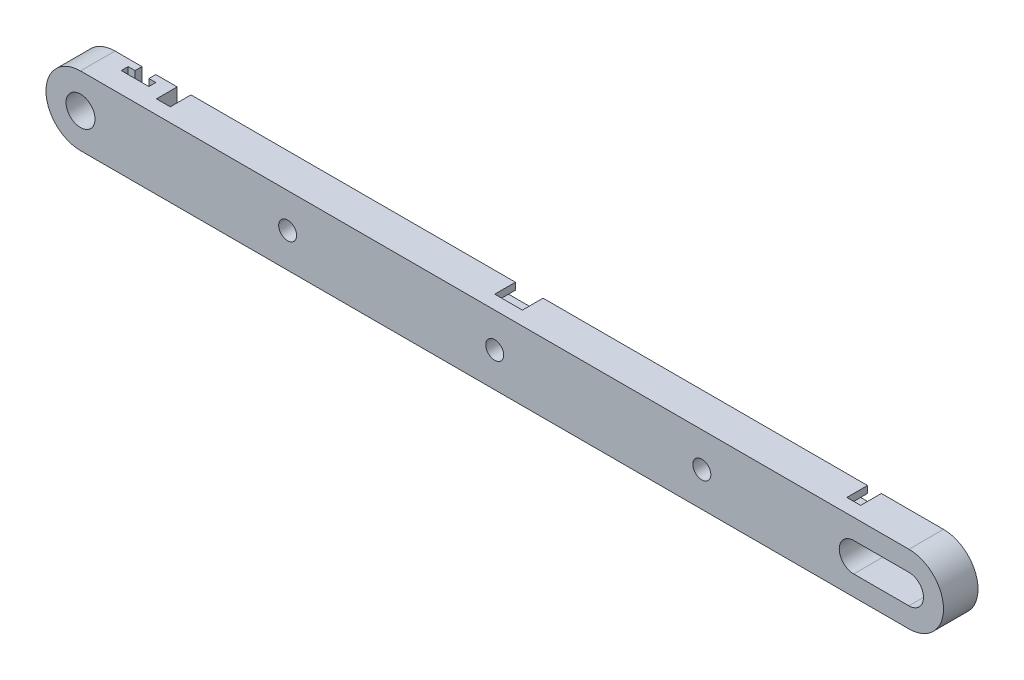
from build123d import *

# Parameters (mm, degrees)
ESQUISSE1_R                  = 10.5
BOSS_EXTRU_1_DEPTH           = 25
ENL_V_START                  = -15
ENL_V_MAT_EXTRU_1_DEPTH      = 35
ENL_V_MAT_EXTRU_2_DEPTH      = 50
ENL_V_MAT_EXTRU_3_DEPTH      = 15
ENL_V_MAT_EXTRU_4_DEPTH      = 626.999201278
ENL_V_MAT_EXTRU_4_DEPTH_BACK = 626.999201278
ESQUISSE1_4_R                = 6.500000002
ESQUISSE1_5_R                = 10.000000002
ENL_V_MAT_EXTRU_5_DEPTH      = 12


with BuildPart() as part:
    # Esquisse1 → Boss.-Extru.1 (new body)
    with BuildSketch(Plane.XY):
        with BuildLine():
            Line((600, -25), (0, -25))
            ThreePointArc((0, -25), (-25, 0), (0, 25))
            Line((0, 25), (600, 25))
            ThreePointArc((600, 25), (625, 0), (600, -25))
        make_face()
        Circle(ESQUISSE1_R, mode=Mode.SUBTRACT)
        with BuildLine():
            Line((560, 10.5), (600, 10.5))
            ThreePointArc((600, 10.5), (610.5, 0), (600, -10.5))
            Line((600, -10.5), (560, -10.5))
            ThreePointArc((560, -10.5), (549.5, 0), (560, 10.5))
        make_face(mode=Mode.SUBTRACT)
    extrude(amount=BOSS_EXTRU_1_DEPTH)

    # Esquisse2 → Enl_v. mat.-Extru.1 (cut)
    with BuildSketch(Plane(origin=(0, 25, 0), x_dir=(1, 0, 0), z_dir=(0, 1, 0)).offset(ENL_V_START)):
        Polygon((510, 0), (500, 0), (500, -5), (495, -5), (495, -10), (515, -10), (515, -5), (510, -5), align=None)
    extrude(amount=-ENL_V_MAT_EXTRU_1_DEPTH, mode=Mode.SUBTRACT)

    # Esquisse3 → Enl_v. mat.-Extru.2 (cut)
    with BuildSketch(Plane.XZ.offset(25)):
        Polygon((19.5, 0), (19.5, 5), (14.5, 5), (14.5, 10), (34.5, 10), (34.5, 5), (29.5, 5), (29.5, 0), align=None)
    extrude(amount=-ENL_V_MAT_EXTRU_2_DEPTH, mode=Mode.SUBTRACT)

    # Esquisse1_3 → Enl_v. mat.-Extru.3 (cut)
    with BuildSketch(Plane.XY):
        Polygon((555, 15), (555, 25), (545, 25), (545, 20), (537.5, 20), (537.5, 15), align=None)
        Polygon((55, 25), (45, 25), (45, 15), (62.5, 15), (62.5, 20), (55, 20), align=None)
        Polygon((310, 20), (310, 25), (290, 25), (290, 20), (282.5, 20), (282.5, 15), (317.5, 15), (317.5, 20), align=None)
    extrude(amount=ENL_V_MAT_EXTRU_3_DEPTH, mode=Mode.SUBTRACT)

    # Esquisse1_4 → Enl_v. mat.-Extru.4 (cut, two sides: drawn at the far end of the back side and taken through both)
    with BuildSketch(Plane.XY.offset(-ENL_V_MAT_EXTRU_4_DEPTH_BACK)):
        with Locations((300, 0)):
            Circle(ESQUISSE1_4_R)
        with Locations((450, 0)):
            Circle(ESQUISSE1_4_R)
        with Locations((150, 0)):
            Circle(ESQUISSE1_4_R)
    extrude(amount=ENL_V_MAT_EXTRU_4_DEPTH + ENL_V_MAT_EXTRU_4_DEPTH_BACK, mode=Mode.SUBTRACT)

    # Esquisse1_5 → Enl_v. mat.-Extru.5 (cut)
    with BuildSketch(Plane.XY):
        with Locations((300, 0)):
            Circle(ESQUISSE1_5_R)
        with Locations((450, 0)):
            Circle(ESQUISSE1_5_R)
        with Locations((150, 0)):
            Circle(ESQUISSE1_5_R)
    extrude(amount=ENL_V_MAT_EXTRU_5_DEPTH, mode=Mode.SUBTRACT)


solid = part.part
